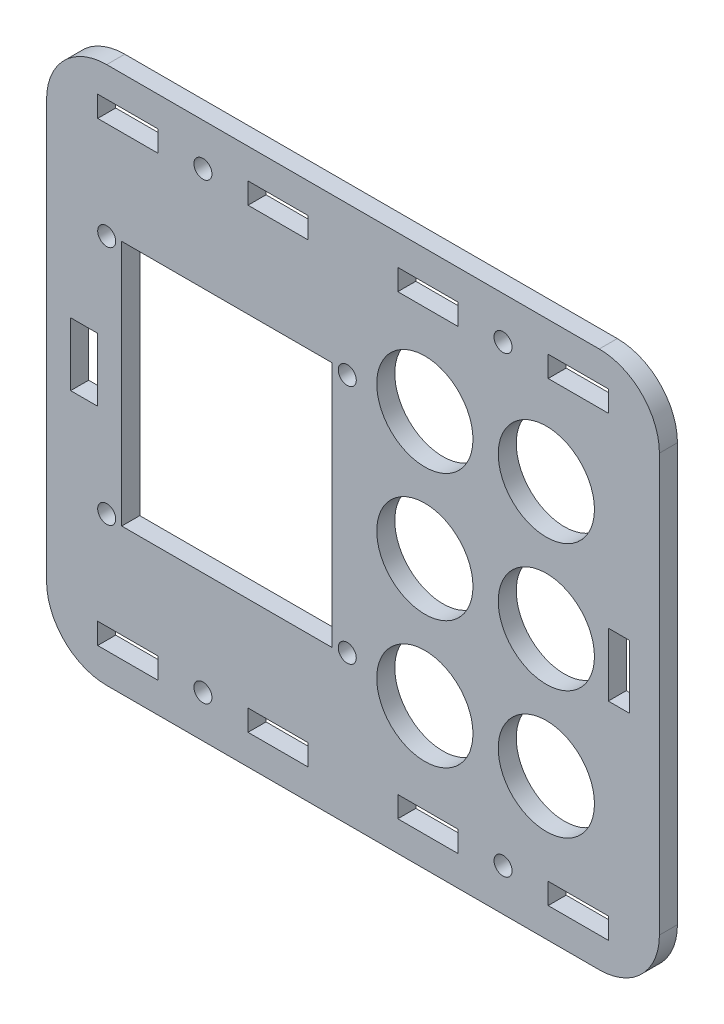
from build123d import *

# Parameters (mm, degrees)
MODEL_R             = 8
MODEL_R_2           = 1.5
MODEL_W             = 10
MODEL_H             = 3.5
MODEL_W_2           = 3.5
MODEL_H_2           = 10.5
MODEL_W_3           = 4.5
MODEL_W_4           = 35
MODEL_H_3           = 41
BOSS_EXTRUDE1_DEPTH = 3


with BuildPart() as part:
    # Model → Boss-Extrude1 (new body)
    with BuildSketch(Plane.XY):
        with BuildLine():
            Line((6.5, 3.5), (88.4, 3.5))
            ThreePointArc((88.4, 3.5), (95.471067812, 0.571067812), (98.4, -6.5))
            Line((98.4, -6.5), (98.4, -75.9))
            ThreePointArc((98.4, -75.9), (95.471067812, -82.971067812), (88.4, -85.9))
            Line((88.4, -85.9), (6.5, -85.9))
            ThreePointArc((6.5, -85.9), (-0.571067812, -82.971067812), (-3.5, -75.9))
            Line((-3.5, -75.9), (-3.5, -6.5))
            ThreePointArc((-3.5, -6.5), (-0.571067812, 0.571067812), (6.5, 3.5))
        make_face()
        with Locations((79.6, -20)):
            Circle(MODEL_R, mode=Mode.SUBTRACT)
        with Locations((79.6, -62.4)):
            Circle(MODEL_R, mode=Mode.SUBTRACT)
        with Locations((79.6, -41.2)):
            Circle(MODEL_R, mode=Mode.SUBTRACT)
        with Locations((46.5, -61.2)):
            Circle(MODEL_R_2, mode=Mode.SUBTRACT)
        with Locations((6.5, -21.2)):
            Circle(MODEL_R_2, mode=Mode.SUBTRACT)
        with Locations((72.4, -78.9)):
            Circle(MODEL_R_2, mode=Mode.SUBTRACT)
        with Locations((22.5, -3.5)):
            Circle(MODEL_R_2, mode=Mode.SUBTRACT)
        with Locations((72.4, -3.5)):
            Circle(MODEL_R_2, mode=Mode.SUBTRACT)
        with Locations((22.5, -78.9)):
            Circle(MODEL_R_2, mode=Mode.SUBTRACT)
        with Locations((6.5, -61.2)):
            Circle(MODEL_R_2, mode=Mode.SUBTRACT)
        with Locations((46.5, -21.2)):
            Circle(MODEL_R_2, mode=Mode.SUBTRACT)
        with Locations((59.4, -41.2)):
            Circle(MODEL_R, mode=Mode.SUBTRACT)
        with Locations((59.4, -62.4)):
            Circle(MODEL_R, mode=Mode.SUBTRACT)
        with Locations((59.4, -20)):
            Circle(MODEL_R, mode=Mode.SUBTRACT)
        with Locations((84.9, -79.15)):
            Rectangle(MODEL_W, MODEL_H, mode=Mode.SUBTRACT)
        with Locations((35, -79.15)):
            Rectangle(MODEL_W, MODEL_H, mode=Mode.SUBTRACT)
        with Locations((84.9, -3.25)):
            Rectangle(MODEL_W, MODEL_H, mode=Mode.SUBTRACT)
        with Locations((35, -3.25)):
            Rectangle(MODEL_W, MODEL_H, mode=Mode.SUBTRACT)
        with Locations((91.65, -41.2)):
            Rectangle(MODEL_W_2, MODEL_H_2, mode=Mode.SUBTRACT)
        with Locations((2.75, -41.2)):
            Rectangle(MODEL_W_3, MODEL_H_2, mode=Mode.SUBTRACT)
        with Locations((10, -3.25)):
            Rectangle(MODEL_W, MODEL_H, mode=Mode.SUBTRACT)
        with Locations((59.9, -3.25)):
            Rectangle(MODEL_W, MODEL_H, mode=Mode.SUBTRACT)
        with Locations((10, -79.15)):
            Rectangle(MODEL_W, MODEL_H, mode=Mode.SUBTRACT)
        with Locations((59.9, -79.15)):
            Rectangle(MODEL_W, MODEL_H, mode=Mode.SUBTRACT)
        with Locations((26.5, -41.2)):
            Rectangle(MODEL_W_4, MODEL_H_3, mode=Mode.SUBTRACT)
    extrude(amount=BOSS_EXTRUDE1_DEPTH)


solid = part.part
